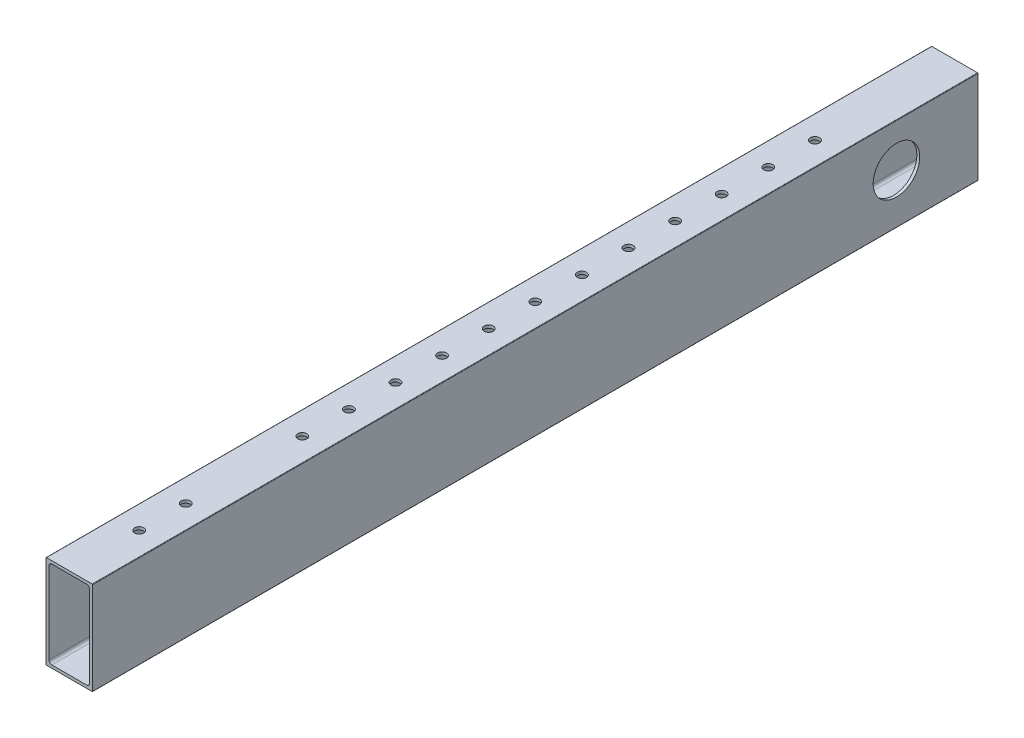
from build123d import *

# Parameters (mm, degrees)
BOSS_EXTRUDE1_DEPTH      = 25.4
BOSS_EXTRUDE1_DEPTH_BACK = 457.2
SKETCH2_R                = 12.7
CUT_EXTRUDE1_DEPTH       = 25.4
SKETCH3_R                = 2.4892
CUT_EXTRUDE2_DEPTH       = 1
CUT_EXTRUDE2_DEPTH_BACK  = 51.8


with BuildPart() as part:
    # Sketch1 → Boss-Extrude1 (new body, two sides)
    with BuildSketch(Plane(origin=(0, 0, 0), x_dir=(-1, 0, 0), z_dir=(0, 0, -1))) as boss_extrude1_sk:
        with BuildLine():
            Line((-12.7, 25.146), (-12.7, -25.146))
            ThreePointArc((-12.7, -25.146), (-12.625605122, -25.325605122), (-12.446, -25.4))
            Line((-12.446, -25.4), (12.446, -25.4))
            ThreePointArc((12.446, -25.4), (12.625605122, -25.325605122), (12.7, -25.146))
            Line((12.7, -25.146), (12.7, 25.146))
            ThreePointArc((12.7, 25.146), (12.625605122, 25.325605122), (12.446, 25.4))
            Line((12.446, 25.4), (-12.446, 25.4))
            ThreePointArc((-12.446, 25.4), (-12.625605122, 25.325605122), (-12.7, 25.146))
        make_face()
        with BuildLine():
            Line((-11.1125, -22.225), (-11.1125, 22.225))
            ThreePointArc((-11.1125, 22.225), (-10.647532015, 23.347532015), (-9.525, 23.8125))
            Line((-9.525, 23.8125), (9.525, 23.8125))
            ThreePointArc((9.525, 23.8125), (10.647532015, 23.347532015), (11.1125, 22.225))
            Line((11.1125, 22.225), (11.1125, -22.225))
            ThreePointArc((11.1125, -22.225), (10.647532015, -23.347532015), (9.525, -23.8125))
            Line((9.525, -23.8125), (-9.525, -23.8125))
            ThreePointArc((-9.525, -23.8125), (-10.647532015, -23.347532015), (-11.1125, -22.225))
        make_face(mode=Mode.SUBTRACT)
    extrude(amount=BOSS_EXTRUDE1_DEPTH)
    extrude(boss_extrude1_sk.sketch, amount=-BOSS_EXTRUDE1_DEPTH_BACK)

    # Sketch2 → Cut-Extrude1 (cut)
    with BuildSketch(Plane.ZY.offset(12.7)):
        with Locations((19.05, 1.778)):
            Circle(SKETCH2_R)
    extrude(amount=-CUT_EXTRUDE1_DEPTH, mode=Mode.SUBTRACT)

    # Sketch3 → Cut-Extrude2 (cut, two sides)
    with BuildSketch(Plane.XZ.offset(25.4)) as cut_extrude2_sk:
        with Locations((0, 50.8)):
            Circle(SKETCH3_R)
        with Locations((0, 76.2)):
            Circle(SKETCH3_R)
        with Locations((0, 101.6)):
            Circle(SKETCH3_R)
        with Locations((0, 127)):
            Circle(SKETCH3_R)
        with Locations((0, 152.4)):
            Circle(SKETCH3_R)
        with Locations((0, 177.8)):
            Circle(SKETCH3_R)
        with Locations((0, 203.2)):
            Circle(SKETCH3_R)
        with Locations((0, 228.6)):
            Circle(SKETCH3_R)
        with Locations((0, 254)):
            Circle(SKETCH3_R)
        with Locations((0, 279.4)):
            Circle(SKETCH3_R)
        with Locations((0, 304.8)):
            Circle(SKETCH3_R)
        with Locations((0, 393.7)):
            Circle(SKETCH3_R)
        with Locations((0, 419.1)):
            Circle(SKETCH3_R)
        with Locations((0, 330.2)):
            Circle(SKETCH3_R)
    extrude(amount=CUT_EXTRUDE2_DEPTH, mode=Mode.SUBTRACT)
    extrude(cut_extrude2_sk.sketch, amount=-CUT_EXTRUDE2_DEPTH_BACK, mode=Mode.SUBTRACT)


solid = part.part
